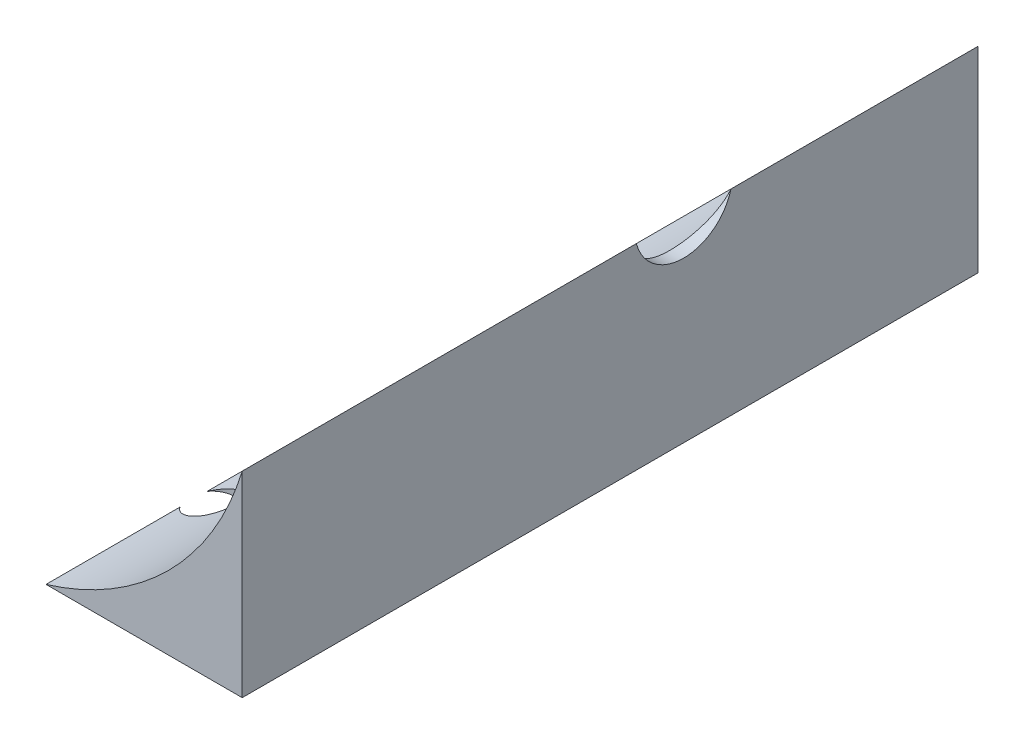
from build123d import *

# Parameters (mm, degrees)
BOSS_EXTRUDE1_DEPTH = 75
SKETCH2_R           = 5
CUT_EXTRUDE1_DEPTH  = 10
SKETCH4_R           = 2.341017376
CUT_EXTRUDE2_DEPTH  = 10


with BuildPart() as part:
    # Sketch1 → Boss-Extrude1 (new body)
    with BuildSketch(Plane.XY):
        with BuildLine():
            Line((0, 0), (0, 20))
            ThreePointArc((0, 20), (-7.495083498, 7.495083498), (-20, 0))
            Line((-20, 0), (0, 0))
        make_face()
    extrude(amount=BOSS_EXTRUDE1_DEPTH)

    # Sketch2 → Cut-Extrude1 (cut)
    with BuildSketch(Plane(origin=(0, 0, 0), x_dir=(0, 0, -1), z_dir=(1, 0, 0))):
        with Locations((-30, 21.3)):
            Circle(SKETCH2_R)
    extrude(amount=-CUT_EXTRUDE1_DEPTH, mode=Mode.SUBTRACT)

    # Sketch4 → Cut-Extrude2 (cut)
    with BuildSketch(Plane(origin=(0, 0, 0), x_dir=(-1, 0, 0), z_dir=(0, -1, 0))):
        with Locations((18.11370574, -59.963970786)):
            Circle(SKETCH4_R)
    extrude(amount=-CUT_EXTRUDE2_DEPTH, mode=Mode.SUBTRACT)


solid = part.part
